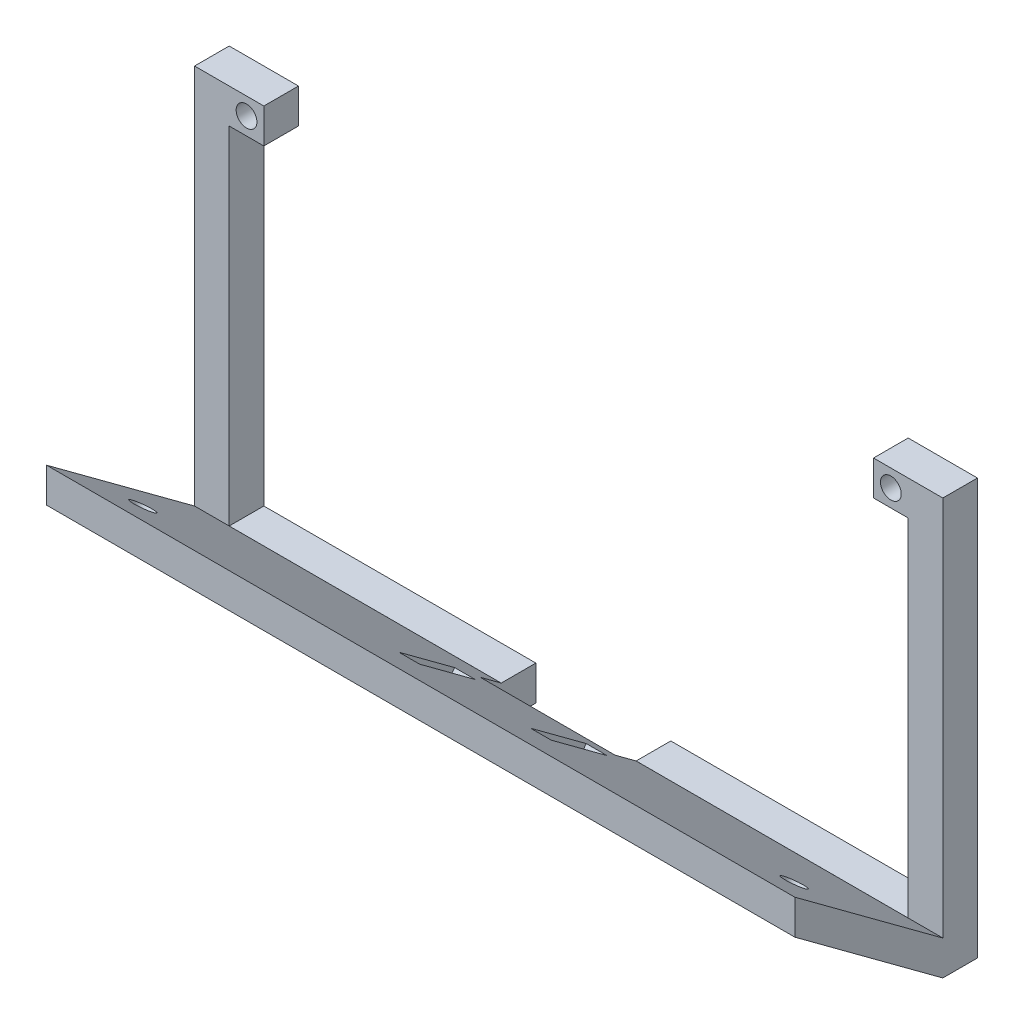
from build123d import *

# Parameters (mm, degrees)
SKETCH3_R           = 1.5
BOSS_EXTRUDE2_DEPTH = 5
BOSS_EXTRUDE3_DEPTH = 108
CUT_EXTRUDE1_REACH  = 53.226
SKETCH5_R           = 1.6
CUT_EXTRUDE2_REACH  = 53.226
SKETCH6_W           = 3
SKETCH6_H           = 10
SKETCH7_W           = 19.472559222
SKETCH7_H           = 21.170747527
CUT_EXTRUDE3_DEPTH  = 61


with BuildPart() as part:
    # Sketch3 → Boss-Extrude2 (new body)
    with BuildSketch(Plane.XY):
        Polygon((-49, 25), (-44, 25), (-44, 30), (-49, 30), (-54, 30), (-54, 25), (-54, -25), (-54, -30), (-49, -30), (-44, -30), (44, -30), (49, -30), (54, -30), (54, -25), (54, 25), (54, 30), (49, 30), (44, 30), (44, 25), (49, 25), (49, -25), (44, -25), (-44, -25), (-49, -25), align=None)
        with BuildLine():
            ThreePointArc((-46.5, -26), (-45.439339828, -26.439339828), (-45, -27.5))
            ThreePointArc((-45, -27.5), (-47.560660172, -28.560660172), (-46.5, -26))
        make_face(mode=Mode.SUBTRACT)
        with Locations((46.5, -27.5)):
            Circle(SKETCH3_R, mode=Mode.SUBTRACT)
        with BuildLine():
            ThreePointArc((-45, 27.5), (-45.439339828, 26.439339828), (-46.5, 26))
            ThreePointArc((-46.5, 26), (-47.560660172, 28.560660172), (-45, 27.5))
        make_face(mode=Mode.SUBTRACT)
        with Locations((46.5, 27.5)):
            Circle(SKETCH3_R, mode=Mode.SUBTRACT)
    extrude(amount=BOSS_EXTRUDE2_DEPTH)

    # Sketch4 → Boss-Extrude3 (add)
    with BuildSketch(Plane(origin=(54, 0, 0), x_dir=(0, 0, -1), z_dir=(1, 0, 0))):
        Polygon((-5, -30), (-5, -25.001535135), (-26.363936199, -9.214733726), (-26.363936199, -14.213198591), align=None)
    extrude(amount=-BOSS_EXTRUDE3_DEPTH)

    # Sketch5 → Cut-Extrude1 (cut, up to next)
    with BuildSketch(Plane(origin=(0, -21.794194287, 16.104739027), x_dir=(-1, 0, 0), z_dir=(0, -0.804246926, 0.594295282)), mode=Mode.PRIVATE) as cut_extrude1_sk1:
        with Locations((47, -7.13269846)):
            Circle(SKETCH5_R)
    cut_extrude1_tool1 = extrude(cut_extrude1_sk1.sketch, amount=-CUT_EXTRUDE1_REACH, mode=Mode.PRIVATE) & part.part
    add(cut_extrude1_tool1.solids().sort_by_distance((-47, -17.555265, 21.84119))[0], mode=Mode.SUBTRACT)
    # Sketch5 → Cut-Extrude1 (cut, up to next)
    with BuildSketch(Plane(origin=(0, -21.794194287, 16.104739027), x_dir=(-1, 0, 0), z_dir=(0, -0.804246926, 0.594295282)), mode=Mode.PRIVATE) as cut_extrude1_sk2:
        with Locations((-47, -7.13269846)):
            Circle(SKETCH5_R)
    cut_extrude1_tool2 = extrude(cut_extrude1_sk2.sketch, amount=-CUT_EXTRUDE1_REACH, mode=Mode.PRIVATE) & part.part
    add(cut_extrude1_tool2.solids().sort_by_distance((47, -17.555265, 21.84119))[0], mode=Mode.SUBTRACT)

    # Sketch6 → Cut-Extrude2 (cut, up to next)
    with BuildSketch(Plane(origin=(0, -21.794194287, 16.104739027), x_dir=(-1, 0, 0), z_dir=(0, -0.804246926, 0.594295282)), mode=Mode.PRIVATE) as cut_extrude2_sk1:
        with Locations((-9.5, -0.964147651)):
            Rectangle(SKETCH6_W, SKETCH6_H)
    cut_extrude2_tool1 = extrude(cut_extrude2_sk1.sketch, amount=-CUT_EXTRUDE2_REACH, mode=Mode.PRIVATE) & part.part
    add(cut_extrude2_tool1.solids().sort_by_distance((9.5, -21.221206, 16.880152))[0], mode=Mode.SUBTRACT)
    # Sketch6 → Cut-Extrude2 (cut, up to next)
    with BuildSketch(Plane(origin=(0, -21.794194287, 16.104739027), x_dir=(-1, 0, 0), z_dir=(0, -0.804246926, 0.594295282)), mode=Mode.PRIVATE) as cut_extrude2_sk2:
        with Locations((9.5, -0.964147651)):
            Rectangle(SKETCH6_W, SKETCH6_H)
    cut_extrude2_tool2 = extrude(cut_extrude2_sk2.sketch, amount=-CUT_EXTRUDE2_REACH, mode=Mode.PRIVATE) & part.part
    add(cut_extrude2_tool2.solids().sort_by_distance((-9.5, -21.221206, 16.880152))[0], mode=Mode.SUBTRACT)

    # Sketch7 → Cut-Extrude3 (cut, through all)
    with BuildSketch(Plane(origin=(0, -30, 0), x_dir=(-1, 0, 0), z_dir=(0, -1, 0))):
        with Locations((0, 2.554576853)):
            Rectangle(SKETCH7_W, SKETCH7_H)
    extrude(amount=-CUT_EXTRUDE3_DEPTH, mode=Mode.SUBTRACT)


solid = part.part
